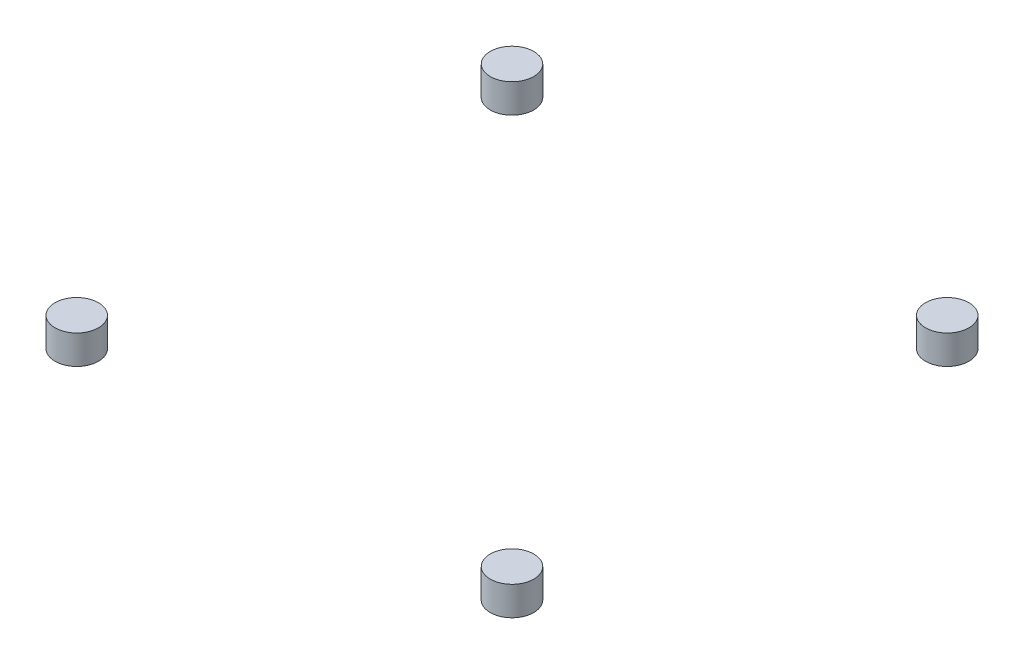
from build123d import *

# Parameters (mm, degrees)
SKETCH1_R             = 7.5
BOSS_EXTRUDE1_DEPTH   = 10
BOSS_EXTRUDE1_2_DEPTH = 10
BOSS_EXTRUDE1_3_DEPTH = 10
BOSS_EXTRUDE1_4_DEPTH = 10


with BuildPart() as part:
    # Sketch1 → Boss-Extrude1 (new body)
    with BuildSketch(Plane(origin=(0, 0, 0), x_dir=(1, 0, 0), z_dir=(0, 1, 0))):
        with Locations((0, 150)):
            Circle(SKETCH1_R)
    extrude(amount=BOSS_EXTRUDE1_DEPTH)


with BuildPart() as body_2:
    # Sketch1 → Boss-Extrude1 2 (new body)
    with BuildSketch(Plane(origin=(0, 0, 0), x_dir=(1, 0, 0), z_dir=(0, 1, 0))):
        with Locations((150, 150)):
            Circle(SKETCH1_R)
    extrude(amount=BOSS_EXTRUDE1_2_DEPTH)


with BuildPart() as body_3:
    # Sketch1 → Boss-Extrude1 3 (new body)
    with BuildSketch(Plane(origin=(0, 0, 0), x_dir=(1, 0, 0), z_dir=(0, 1, 0))):
        with Locations((150, 0)):
            Circle(SKETCH1_R)
    extrude(amount=BOSS_EXTRUDE1_3_DEPTH)


with BuildPart() as body_4:
    # Sketch1 → Boss-Extrude1 4 (new body)
    with BuildSketch(Plane(origin=(0, 0, 0), x_dir=(1, 0, 0), z_dir=(0, 1, 0))):
        Circle(SKETCH1_R)
    extrude(amount=BOSS_EXTRUDE1_4_DEPTH)


solid = Compound([part.part, body_2.part, body_3.part, body_4.part])
